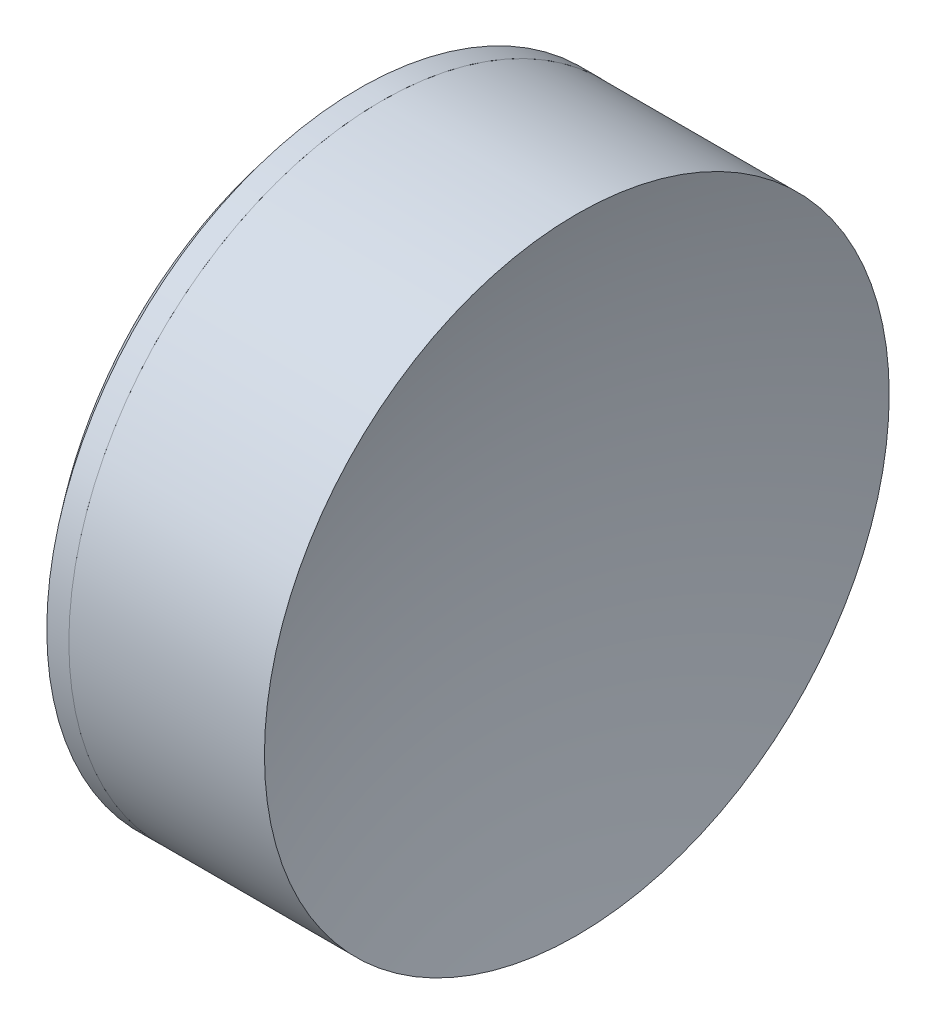
from build123d import *


with BuildPart() as part:
    # 草图1 one side → 旋转1 (revolve)
    with BuildSketch(Plane(origin=(0, 0, 0), x_dir=(1, 0, 0), z_dir=(0, 1, 0)), mode=Mode.PRIVATE) as revolve_1_sk:
        with BuildLine():
            ThreePointArc((102.505109216, 25.4), (95.635460924, 13.516909249), (93.249443783, 0))
            Line((93.249443783, 0), (111.249443783, 0))
            ThreePointArc((111.249443783, 0), (109.480611879, 13.166825018), (104.299542758, 25.4))
            Line((104.299542758, 25.4), (102.505109216, 25.4))
        make_face()
    revolve(revolve_1_sk.sketch.rotate(Axis((-0.816062176, 0, 0), (1, 0, 0)), 180), axis=Axis((-0.816062176, 0, 0), (1, 0, 0)))  # turned: the seam where the file's is


with BuildPart() as body_2:
    # 草图2 one side → 旋转2 (revolve)
    with BuildSketch(Plane(origin=(0, 0, 0), x_dir=(1, 0, 0), z_dir=(0, 1, 0)), mode=Mode.PRIVATE) as revolve_2_sk:
        with BuildLine():
            Line((120.20146829, 25.4), (104.299542758, 25.4))
            ThreePointArc((104.299542758, 25.4), (109.480611879, 13.166825018), (111.249443783, 0))
            Line((111.249443783, 0), (116.249443783, 0))
            ThreePointArc((116.249443783, 0), (117.243358198, 12.852806092), (120.20146829, 25.4))
        make_face()
    revolve(revolve_2_sk.sketch.rotate(Axis((-0.551919993, 0, 0), (1, 0, 0)), 180), axis=Axis((-0.551919993, 0, 0), (1, 0, 0)))  # turned: the seam where the file's is


solid = Compound([part.part, body_2.part])
